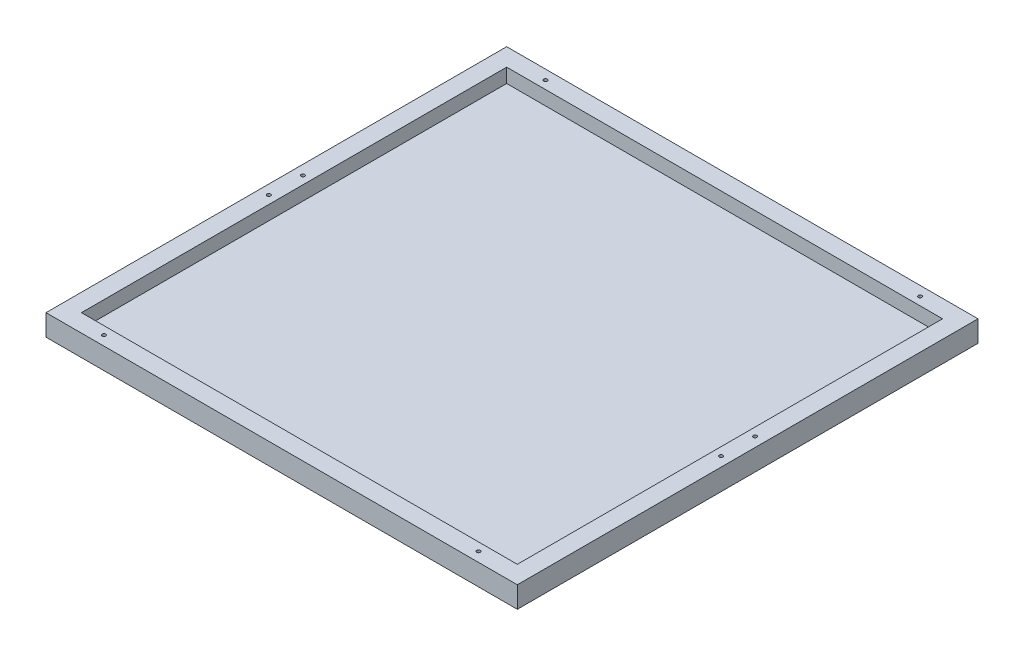
from build123d import *

# Parameters (mm, degrees)
SKETCH1_W                      = 665
SKETCH1_H                      = 650
BOSS_EXTRUDE1_DEPTH            = 30
F_8_0_199_DIAMETER_HOLE1_D     = 5.0546
F_8_0_199_DIAMETER_HOLE1_DEPTH = 9.65
SKETCH4_W                      = 615
SKETCH4_H                      = 600
CUT_EXTRUDE1_DEPTH             = 20


with BuildPart() as part:
    # Sketch1 → Boss-Extrude1 (new body)
    with BuildSketch(Plane(origin=(0, 0, 0), x_dir=(1, 0, 0), z_dir=(0, 1, 0))):
        with Locations((332.5, 325)):
            Rectangle(SKETCH1_W, SKETCH1_H)
    extrude(amount=-BOSS_EXTRUDE1_DEPTH)

    # #8 (0.199) Diameter Hole1
    with Locations(Plane(origin=(0, 0, 0), x_dir=(1, 0, 0), z_dir=(0, 1, 0))):
        with Locations((68.25, 13.5), (13.5, 301), (596.75, 13.5), (651.5, 301), (651.5, 349), (596.75, 636.5), (68.25, 636.5), (13.5, 349)):
            Hole(F_8_0_199_DIAMETER_HOLE1_D / 2, depth=F_8_0_199_DIAMETER_HOLE1_DEPTH)

    # Sketch4 → Cut-Extrude1 (cut)
    with BuildSketch(Plane(origin=(0, 0, 0), x_dir=(1, 0, 0), z_dir=(0, 1, 0))):
        with Locations((332.5, 325)):
            Rectangle(SKETCH4_W, SKETCH4_H)
    extrude(amount=-CUT_EXTRUDE1_DEPTH, mode=Mode.SUBTRACT)


solid = part.part
